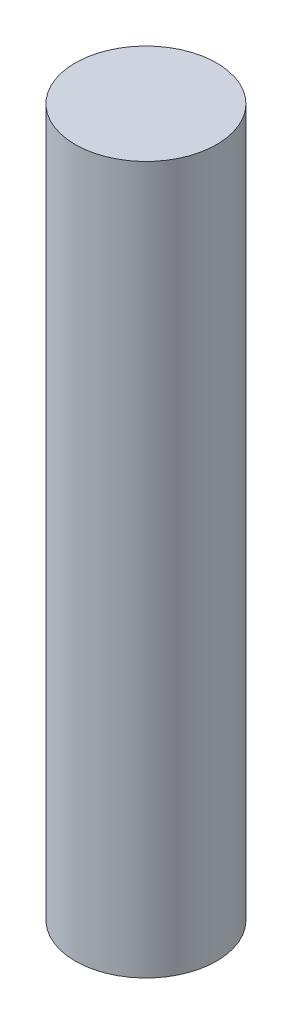
from build123d import *

# Parameters (mm, degrees)
SKETCH1_R           = 4.5
BOSS_EXTRUDE1_DEPTH = 45


with BuildPart() as part:
    # Sketch1 → Boss-Extrude1 (new body)
    with BuildSketch(Plane(origin=(0, 0, 0), x_dir=(1, 0, 0), z_dir=(0, 1, 0))):
        Circle(SKETCH1_R)
    extrude(amount=BOSS_EXTRUDE1_DEPTH)


solid = part.part
